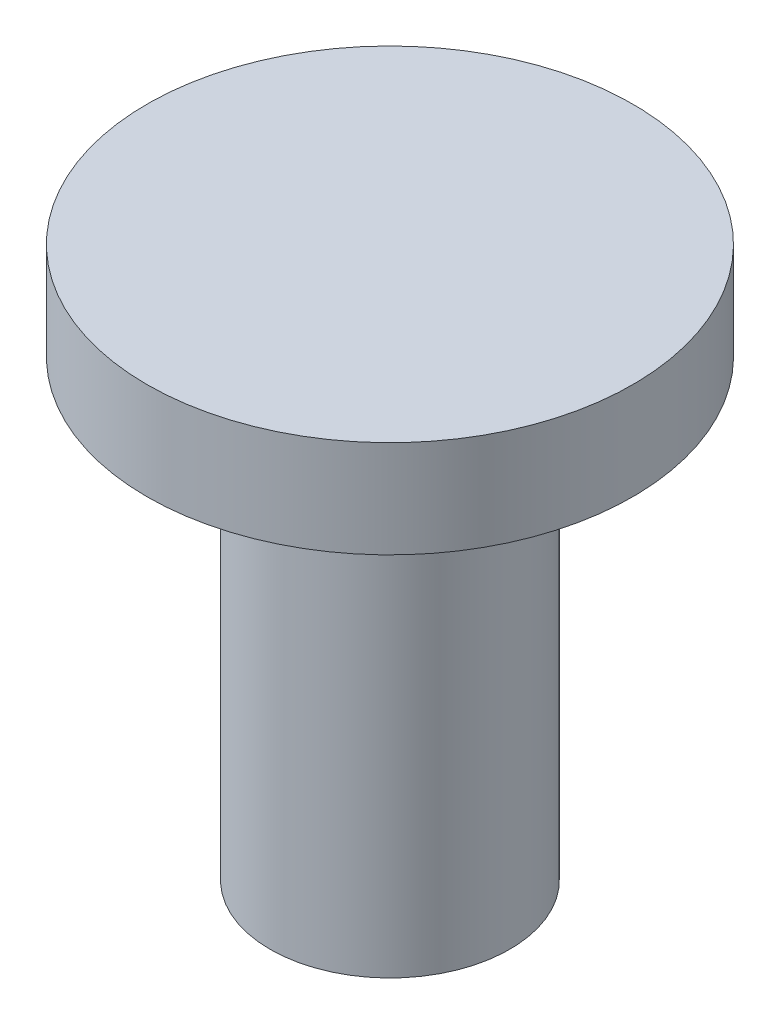
from build123d import *


with BuildPart() as part:
    # Sketch2 → Revolve1 (revolve)
    with BuildSketch(Plane(origin=(0, 0, 0), x_dir=(0, 0, -1), z_dir=(1, 0, 0))):
        Polygon((2.052486188, 9.422651934), (-5.447513812, 9.422651934), (-5.447513812, 6.422651934), (-1.647513812, 6.422651934), (-1.647513812, -7.577348066), (2.052486188, -7.577348066), align=None)
    revolve(axis=Axis((0, 9.422651934, -2.052486188), (0, -1, 0)))


solid = part.part
